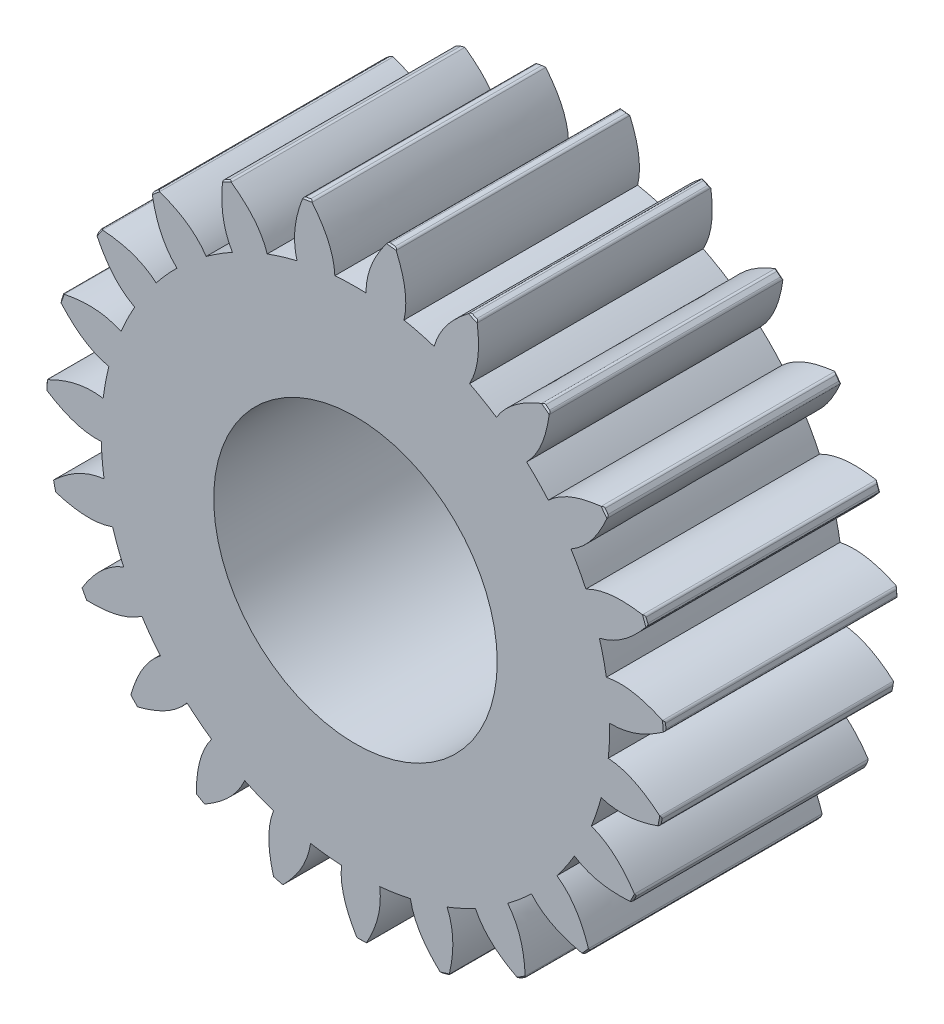
from build123d import *

# Parameters (mm, degrees)
BOSS_EXTRUDE2_DEPTH          = 32.97
CHAMFER1_SIZE                = 0.2
FILLET1_R                    = 0.4
CIRPATTERN1_COUNT            = 23
CHAMFER1_OF_CIRPATTERN1_SIZE = 0.2
FILLET1_OF_CIRPATTERN1_R     = 0.4
SKETCH2_R                    = 20
CUT_EXTRUDE1_DEPTH           = 33.9700001


with BuildPart() as part:
    # Sketch1 → Boss-Extrude2 (new body)
    with BuildSketch(Plane.XY):
        with BuildLine():
            ThreePointArc((-8.249646713, 34.913592684), (5.596802654, -35.435736553), (-2.912168899, 35.756606345))
            add(Edge.make_bspline(
                [(-2.912168899, 35.756606345), (-2.960462278, 36.910481192), (-3.597223007, 39.575454002), (-5.158610007, 41.941336089), (-6.224041951, 43.246134183), (-6.267375068, 43.298758755)],
                knots=[-0.066907858, -0.066907858, -0.066907858, -0.066907858, 0.062650539, 0.250153782, 0.258063963, 0.258063963, 0.258063963, 0.258063963], degree=3))
            ThreePointArc((-6.267375068, 43.298758755), (-6.825369089, 43.21431287), (-7.38222741, 43.122676383))
            add(Edge.make_bspline(
                [(-7.38222741, 43.122676383), (-7.407232484, 43.059258317), (-8.018668121, 41.489611544), (-8.774894399, 38.75768067), (-8.559324268, 36.026183884), (-8.249646713, 34.913592684)],
                knots=[0, 0, 0, 0, 0.007910179, 0.195413422, 0.324971819, 0.324971819, 0.324971819, 0.324971819], degree=3))
        make_face()
    boss_extrude2 = extrude(amount=BOSS_EXTRUDE2_DEPTH)

    # Chamfer1
    chamfer1_edges = [part.edges().sort_by_distance(p)[0] for p in [
        (-6.825369089, 43.21431287, 32.97),
        (-6.825369089, 43.21431287, 0),
    ]]
    chamfer(chamfer1_edges, length=CHAMFER1_SIZE)

    # Fillet1
    fillet1_edges = [part.edges().sort_by_distance(p)[0] for p in [
        (-7.38222741, 43.122676383, 16.485),
        (-6.267375068, 43.298758755, 16.485),
    ]]
    fillet(fillet1_edges, radius=FILLET1_R)

    # CirPattern1: Boss-Extrude2 ×23 about axis
    cirpattern1_axis = Axis((0, 0, 0), (0, 0, -1))
    for i in range(1, CIRPATTERN1_COUNT):
        add(boss_extrude2.rotate(cirpattern1_axis, i * 360 / CIRPATTERN1_COUNT))

    # Chamfer1 of CirPattern1
    chamfer1_of_cirpattern1_edges = [part.edges().sort_by_distance(p)[0] for p in [
        (5.086816192, 43.453271465, 32.97),
        (5.086816192, 43.453271465, 0),
        (16.621735586, 40.469499702, 32.97),
        (16.621735586, 40.469499702, 0),
        (26.923896891, 34.484290281, 32.97),
        (26.923896891, 34.484290281, 0),
        (35.229235933, 25.941538805, 32.97),
        (35.229235933, 25.941538805, 0),
        (40.921783708, 15.474822071, 32.97),
        (40.921783708, 15.474822071, 0),
        (43.579349991, 3.860408576, 32.97),
        (43.579349991, 3.860408576, 0),
        (43.004835247, -8.040313762, 32.97),
        (43.004835247, -8.040313762, 0),
        (39.240848606, -19.344722811, 32.97),
        (39.240848606, -19.344722811, 0),
        (32.56654774, -29.214422265, 32.97),
        (32.56654774, -29.214422265, 0),
        (23.47693501, -36.917421667, 32.97),
        (23.47693501, -36.917421667, 0),
        (12.646145409, -41.88242479, 32.97),
        (12.646145409, -41.88242479, 0),
        (0.877449057, -43.741200065, 32.97),
        (0.877449057, -43.741200065, 0),
        (-10.956323679, -42.355890635, 32.97),
        (-10.956323679, -42.355890635, 0),
        (-21.977516009, -37.829238561, 32.97),
        (-21.977516009, -37.829238561, 0),
        (-31.368736517, -30.49696492, 32.97),
        (-31.368736517, -30.49696492, 0),
        (-38.43348134, -20.902870906, 32.97),
        (-38.43348134, -20.902870906, 0),
        (-42.647790673, -9.75850658, 32.97),
        (-42.647790673, -9.75850658, 0),
        (-43.699108473, 2.109601536, 32.97),
        (-43.699108473, 2.109601536, 0),
        (-41.509463308, 13.821250157, 32.97),
        (-41.509463308, 13.821250157, 0),
        (-36.241251142, 24.507839882, 32.97),
        (-36.241251142, 24.507839882, 0),
        (-28.285191172, 33.376795238, 32.97),
        (-28.285191172, 33.376795238, 0),
        (-18.231347968, 39.770346381, 32.97),
        (-18.231347968, 39.770346381, 0),
    ]]
    chamfer(chamfer1_of_cirpattern1_edges, length=CHAMFER1_OF_CIRPATTERN1_SIZE)

    # Fillet1 of CirPattern1
    fillet1_of_cirpattern1_edges = [part.edges().sort_by_distance(p)[0] for p in [
        (4.525884459, 43.515271685, 16.485),
        (5.646901509, 43.384040883, 16.485),
        (16.098332183, 40.680538356, 16.485),
        (17.142373233, 40.251727167, 16.485),
        (26.476840254, 34.828715597, 16.485),
        (27.366473555, 34.134126987, 16.485),
        (34.891682207, 26.393806334, 16.485),
        (35.560927727, 25.484954761, 16.485),
        (40.718767709, 16.001389198, 16.485),
        (41.11799057, 14.945680027, 16.485),
        (43.525928486, 4.422222227, 16.485),
        (43.625520155, 3.297952577, 16.485),
        (43.104970265, -7.484920736, 16.485),
        (42.897544483, -8.594368929, 16.485),
        (39.487113592, -18.83694137, 16.485),
        (38.988054181, -19.849285408, 16.485),
        (32.940678345, -28.791912235, 16.485),
        (32.186998258, -29.632071192, 16.485),
        (23.951183679, -36.611518684, 16.485),
        (22.99877992, -37.217181814, 16.485),
        (13.185339289, -41.715816279, 16.485),
        (12.104847288, -42.042064318, 16.485),
        (1.441598603, -43.726242618, 16.485),
        (0.313153508, -43.748879241, 16.485),
        (-10.409058857, -42.493693576, 16.485),
        (-11.501765434, -42.211039929, 16.485),
        (-21.48772404, -38.109581677, 16.485),
        (-22.463651052, -37.542600888, 16.485),
        (-30.97274303, -30.899056445, 16.485),
        (-31.759510435, -30.089798885, 16.485),
        (-38.160655361, -21.39688955, 16.485),
        (-38.69991222, -20.40537415, 16.485),
        (-42.518366457, -10.307813242, 16.485),
        (-42.770118555, -9.207576163, 16.485),
        (-43.722684822, 1.54574642, 16.485),
        (-43.668260857, 2.673105626, 16.485),
        (-41.684291671, 13.284665141, 16.485),
        (-41.327728021, 14.3555354, 16.485),
        (-36.5543653, 24.038321021, 16.485),
        (-35.922106659, 24.973280785, 16.485),
        (-28.71336888, 33.0091646, 16.485),
        (-27.852306979, 33.738872179, 16.485),
        (-18.742833244, 39.531869447, 16.485),
        (-17.716829106, 40.002205769, 16.485),
    ]]
    fillet(fillet1_of_cirpattern1_edges, radius=FILLET1_OF_CIRPATTERN1_R)

    # Sketch2 → Cut-Extrude1 (cut, through all)
    with BuildSketch(Plane.XY.offset(32.97)):
        Circle(SKETCH2_R)
    extrude(amount=-CUT_EXTRUDE1_DEPTH, mode=Mode.SUBTRACT)


solid = part.part
